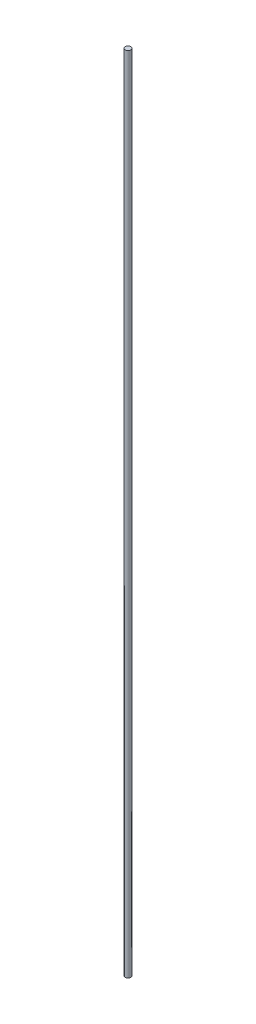
from build123d import *

# Parameters (mm, degrees)
SKETCH1_R           = 1.5
BOSS_EXTRUDE1_DEPTH = 424


with BuildPart() as part:
    # Sketch1 → Boss-Extrude1 (new body)
    with BuildSketch(Plane(origin=(0, 0, 0), x_dir=(1, 0, 0), z_dir=(0, 1, 0))):
        Circle(SKETCH1_R)
    extrude(amount=BOSS_EXTRUDE1_DEPTH)


solid = part.part
